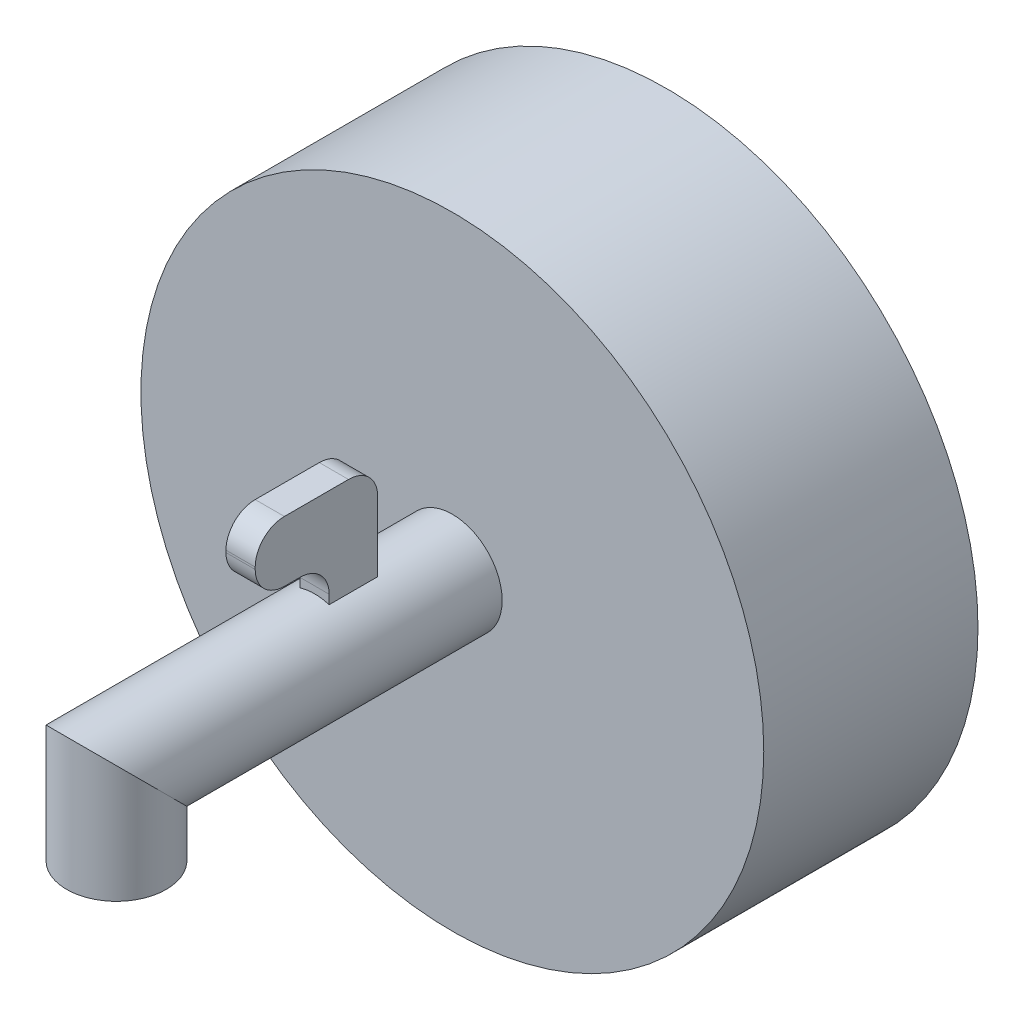
from build123d import *

# Parameters (mm, degrees)
SKETCH1_R                = 31.980898523
SKETCH1_R_2              = 25.45
BOSS_EXTRUDE1_DEPTH      = 20
SKETCH2_R                = 31.980898523
BOSS_EXTRUDE2_DEPTH      = 2
SKETCH3_R                = 5.114403944
BOSS_EXTRUDE3_DEPTH      = 1.5
BOSS_EXTRUDE3_DEPTH_BACK = 1.5


with BuildPart() as part:
    # Sketch1 → Boss-Extrude1 (new body)
    with BuildSketch(Plane.XY):
        Circle(SKETCH1_R)
        Circle(SKETCH1_R_2, mode=Mode.SUBTRACT)
    extrude(amount=BOSS_EXTRUDE1_DEPTH)

    # Sketch2 → Boss-Extrude2 (add)
    with BuildSketch(Plane.XY.offset(20)):
        Circle(SKETCH2_R)
    extrude(amount=BOSS_EXTRUDE2_DEPTH)

    # Sweep2: sweep along a path in Sketch4
    with BuildLine(Plane(origin=(0, 0, 0), x_dir=(0, 0, -1), z_dir=(1, 0, 0))) as sweep2_path:
        Line((-22, 0), (-56.496170036, 0))
        Line((-56.496170036, 0), (-56.496170036, -8.454631323))
    # Sketch3 → Sweep2 (sweep)
    with BuildSketch(Plane.XY.offset(22)):
        Circle(SKETCH3_R)
    sweep(path=sweep2_path.line, transition=Transition.RIGHT)

    # Sketch5 → Boss-Extrude3 (add, two sides: drawn at the far end of the back side and taken through both)
    with BuildSketch(Plane(origin=(0, 0, 0), x_dir=(0, 0, -1), z_dir=(1, 0, 0)).offset(-BOSS_EXTRUDE3_DEPTH_BACK)):
        with BuildLine():
            Line((-36.150092228, 0), (-36.150092228, 5.823788286))
            ThreePointArc((-36.150092228, 5.823788286), (-37.028771884, 7.94510863), (-39.150092228, 8.823788286))
            Line((-39.150092228, 8.823788286), (-40.746223013, 8.823788286))
            ThreePointArc((-40.746223013, 8.823788286), (-42.867543357, 9.702467943), (-43.746223013, 11.823788286))
            Line((-43.746223013, 11.823788286), (-43.746223013, 12.038804384))
            ThreePointArc((-43.746223013, 12.038804384), (-42.867543357, 14.160124727), (-40.746223013, 15.038804384))
            Line((-40.746223013, 15.038804384), (-34.162733631, 15.038804384))
            ThreePointArc((-34.162733631, 15.038804384), (-32.041413287, 14.160124727), (-31.162733631, 12.038804384))
            Line((-31.162733631, 12.038804384), (-31.162733631, 0))
            Line((-31.162733631, 0), (-36.150092228, 0))
        make_face()
    extrude(amount=BOSS_EXTRUDE3_DEPTH + BOSS_EXTRUDE3_DEPTH_BACK)


solid = part.part
